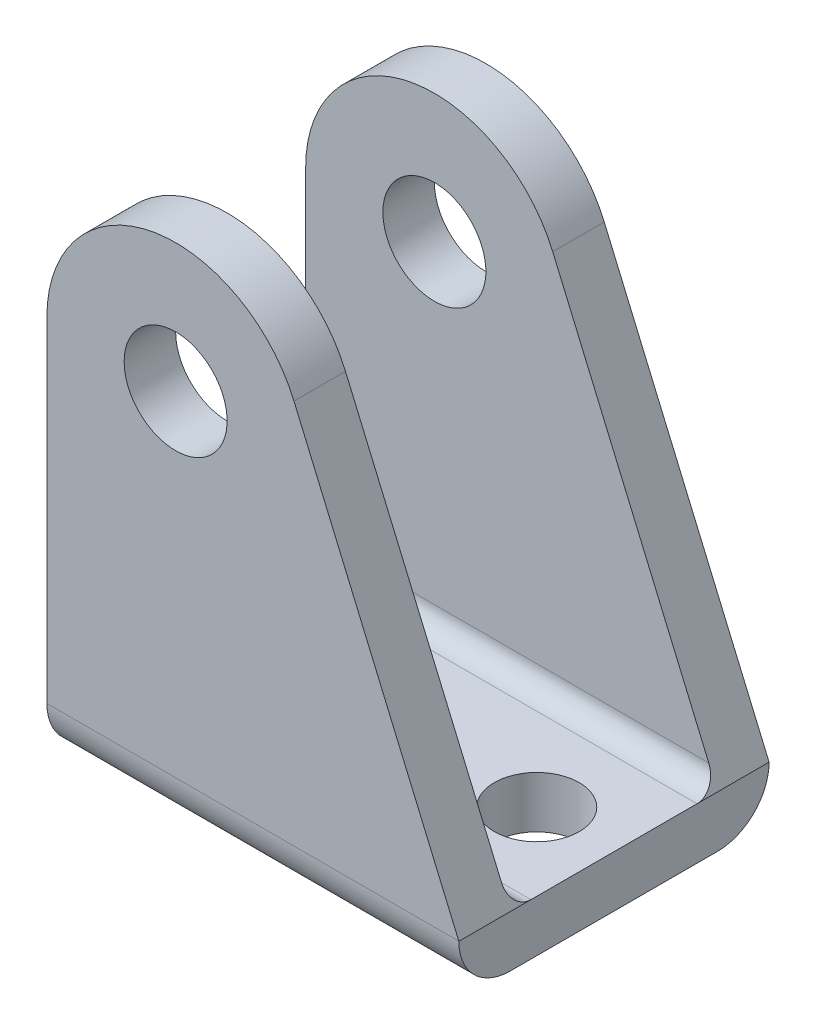
from build123d import *

# Parameters (mm, degrees)
BOSS_EXTRUDE1_DEPTH      = 32
BOSS_EXTRUDE1_DEPTH_BACK = 32
CUT_EXTRUDE1_DEPTH       = 32
CUT_EXTRUDE1_DEPTH_BACK  = 32
SKETCH2_W                = 96.2
SKETCH2_H                = 76.1
CUT_EXTRUDE2_DEPTH       = 16.1
CUT_EXTRUDE2_DEPTH_BACK  = 16.1
SKETCH3_R                = 4
CUT_EXTRUDE3_DEPTH       = 4
CUT_EXTRUDE3_DEPTH_BACK  = 4
SKETCH4_R                = 3.3
CUT_EXTRUDE4_DEPTH       = 4
CUT_EXTRUDE4_DEPTH_BACK  = 4
SKETCH5_R                = 3.3


with BuildPart() as part:
    # Sketch1 → Boss-Extrude1 (new, two sides: drawn at the far end of the back side and taken through both)
    with BuildSketch(Plane(origin=(0, 0, 0), x_dir=(0, 0, -1), z_dir=(1, 0, 0)).offset(-BOSS_EXTRUDE1_DEPTH_BACK)):
        with BuildLine():
            Line((-8.05, 0), (8.05, 0))
            ThreePointArc((8.05, 0), (10.878427125, 1.171572875), (12.05, 4))
            Line((12.05, 4), (12.05, 40))
            Line((12.05, 40), (8.05, 40))
            Line((8.05, 40), (8.05, 5.6))
            ThreePointArc((8.05, 5.6), (7.58137085, 4.46862915), (6.45, 4))
            Line((6.45, 4), (-6.45, 4))
            ThreePointArc((-6.45, 4), (-7.58137085, 4.46862915), (-8.05, 5.6))
            Line((-8.05, 5.6), (-8.05, 40))
            Line((-8.05, 40), (-12.05, 40))
            Line((-12.05, 40), (-12.05, 4))
            ThreePointArc((-12.05, 4), (-10.878427125, 1.171572875), (-8.05, 0))
        make_face()
    extrude(amount=BOSS_EXTRUDE1_DEPTH + BOSS_EXTRUDE1_DEPTH_BACK)

    # Sketch2 → Cut-Extrude1 (cut, two sides: drawn at the far end of the back side and taken through both)
    with BuildSketch(Plane.XY.offset(-CUT_EXTRUDE1_DEPTH_BACK)):
        with Locations((0, 21.95)):
            Rectangle(SKETCH2_W, SKETCH2_H)
        with BuildLine():
            Line((0, 30), (0, 0))
            Line((0, 0), (32, 0))
            Line((32, 0), (32, 4))
            Line((32, 4), (19.19395406, 33.933345743))
            ThreePointArc((19.19395406, 33.933345743), (7.9924568, 39.796416197), (0, 30))
        make_face(mode=Mode.SUBTRACT)
    extrude(amount=CUT_EXTRUDE1_DEPTH + CUT_EXTRUDE1_DEPTH_BACK, mode=Mode.SUBTRACT)

    # Sketch3 → Cut-Extrude2 (cut, two sides: drawn at the far end of the back side and taken through both)
    with BuildSketch(Plane.XY.offset(-CUT_EXTRUDE2_DEPTH_BACK)):
        with Locations((10, 30)):
            Circle(SKETCH3_R)
    extrude(amount=CUT_EXTRUDE2_DEPTH + CUT_EXTRUDE2_DEPTH_BACK, mode=Mode.SUBTRACT)

    # Sketch4 → Cut-Extrude3 (cut, two sides: drawn at the far end of the back side and taken through both)
    with BuildSketch(Plane(origin=(0, 0, 0), x_dir=(1, 0, 0), z_dir=(0, 1, 0)).offset(-CUT_EXTRUDE3_DEPTH_BACK)):
        with Locations((6, 0)):
            Circle(SKETCH4_R)
    extrude(amount=CUT_EXTRUDE3_DEPTH + CUT_EXTRUDE3_DEPTH_BACK, mode=Mode.SUBTRACT)

    # Sketch5 → Cut-Extrude4 (cut, two sides: drawn at the far end of the back side and taken through both)
    with BuildSketch(Plane(origin=(0, 0, 0), x_dir=(1, 0, 0), z_dir=(0, 1, 0)).offset(-CUT_EXTRUDE4_DEPTH_BACK)):
        with Locations((26, 0)):
            Circle(SKETCH5_R)
    extrude(amount=CUT_EXTRUDE4_DEPTH + CUT_EXTRUDE4_DEPTH_BACK, mode=Mode.SUBTRACT)


solid = part.part
